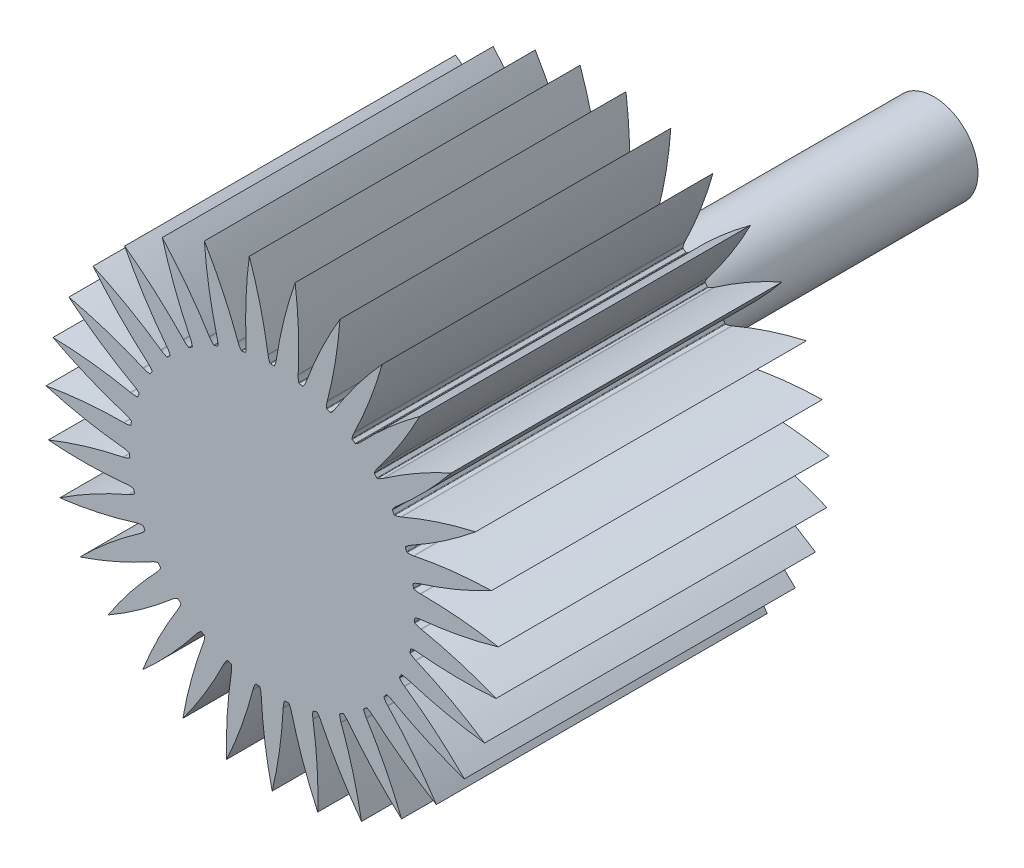
from build123d import *

# Parameters (mm, degrees)
SKETCH1_R                = 500
EXTRUDE1_DEPTH           = 300
CUT_EXTRUDE1_START       = -301
CUT_EXTRUDE1_DEPTH       = 302
FILLET1_R                = 0.635
CIRPATTERN1_COUNT        = 31
FILLET1_OF_CIRPATTERN1_R = 0.635
SKETCH3_R                = 40
EXTRUDE2_DEPTH           = 300


with BuildPart() as part:
    # Sketch1 → Extrude1 (new body)
    with BuildSketch(Plane.XY):
        Circle(SKETCH1_R)
    extrude(amount=EXTRUDE1_DEPTH)

    # Sketch2 → Cut-Extrude1 (cut)
    with BuildSketch(Plane.XY.offset(300).offset(CUT_EXTRUDE1_START)):
        with BuildLine():
            Line((-2460.940364062, 1353.146977655), (-241.231460808, 437.958196997))
            ThreePointArc((-241.231460808, 437.958196997), (-82.810970136, 318.022108626), (-3.81, 135.702159428))
            Line((-3.81, 135.702159428), (-3.732214889, 135.194159428))
            ThreePointArc((-3.732214889, 135.194159428), (-3.039845854, 132.203962215), (-1.905, 129.352159428))
            ThreePointArc((-1.905, 129.352159428), (0, 129.366186361), (1.905, 129.352159428))
            ThreePointArc((1.905, 129.352159428), (3.039845854, 132.203962215), (3.732214889, 135.194159428))
            Line((3.732214889, 135.194159428), (3.81, 135.702159428))
            ThreePointArc((3.81, 135.702159428), (82.810970136, 318.022108626), (241.231460808, 437.958196997))
            Line((241.231460808, 437.958196997), (2460.940364062, 1353.146977655))
            Line((2460.940364062, 1353.146977655), (2460.940364062, 6155.095798467))
            Line((2460.940364062, 6155.095798467), (-2460.940364062, 6155.095798467))
            Line((-2460.940364062, 6155.095798467), (-2460.940364062, 1353.146977655))
        make_face()
    cut_extrude1 = extrude(amount=CUT_EXTRUDE1_DEPTH, mode=Mode.SUBTRACT)

    # Fillet1
    fillet1_edges = [part.edges().sort_by_distance(p)[0] for p in [
        (1.905, 129.352159428, 150),
        (-1.905, 129.352159428, 150),
    ]]
    fillet(fillet1_edges, radius=FILLET1_R)

    # CirPattern1: Cut-Extrude1 ×31 about axis
    cirpattern1_axis = Axis((0, 0, 0), (0, 0, 1))
    for i in range(1, CIRPATTERN1_COUNT):
        add(cut_extrude1.rotate(cirpattern1_axis, i * 360 / CIRPATTERN1_COUNT), mode=Mode.SUBTRACT)

    # Fillet1 of CirPattern1
    fillet1_of_cirpattern1_edges = [part.edges().sort_by_distance(p)[0] for p in [
        (-24.172393725, 127.087786806, 150),
        (-27.904402801, 126.320839444, 150),
        (-49.260166811, 119.62042526, 150),
        (-52.761396073, 118.117929452, 150),
        (-72.331222879, 107.255789449, 150),
        (-75.45833159, 105.07925755, 150),
        (-92.441030185, 90.500089016, 150),
        (-95.065994147, 87.738628497, 150),
        (-108.766290853, 70.039304306, 150),
        (-110.781643733, 66.805969685, 150),
        (-120.638646795, 46.711102248, 150),
        (-121.961879808, 43.138266624, 150),
        (-127.572042362, 21.470542175, 150),
        (-128.148982194, 17.70447786, 150),
        (-129.282623525, -4.649024416, 150),
        (-129.089650192, -8.454134309, 150),
        (-125.700358892, -30.578259402, 150),
        (-124.745372744, -34.266633225, 150),
        (-116.971906796, -55.255616855, 150),
        (-115.294005079, -58.676252151, 150),
        (-103.454611093, -77.670802862, 150),
        (-101.122487299, -80.68365842, 150),
        (-85.701871456, -96.906137074, 150),
        (-82.811003008, -99.387866233, 150),
        (-64.440487132, -112.174122648, 150),
        (-61.109226524, -114.023123125, 150),
        (-40.540901693, -122.849686461, 150),
        (-36.905631126, -123.990259959, 150),
        (-14.981566976, -128.495769676, 150),
        (-11.191114854, -128.881220983, 150),
        (11.191114854, -128.881220983, 150),
        (14.981566976, -128.495769676, 150),
        (36.905631126, -123.990259959, 150),
        (40.540901693, -122.849686461, 150),
        (61.109226524, -114.023123125, 150),
        (64.440487132, -112.174122648, 150),
        (82.811003008, -99.387866233, 150),
        (85.701871456, -96.906137074, 150),
        (101.122487299, -80.68365842, 150),
        (103.454611093, -77.670802862, 150),
        (115.294005079, -58.676252151, 150),
        (116.971906796, -55.255616855, 150),
        (124.745372744, -34.266633225, 150),
        (125.700358892, -30.578259402, 150),
        (129.089650192, -8.454134309, 150),
        (129.282623525, -4.649024416, 150),
        (128.148982194, 17.70447786, 150),
        (127.572042362, 21.470542175, 150),
        (121.961879808, 43.138266624, 150),
        (120.638646795, 46.711102248, 150),
        (110.781643733, 66.805969685, 150),
        (108.766290853, 70.039304306, 150),
        (95.065994147, 87.738628497, 150),
        (92.441030185, 90.500089016, 150),
        (75.45833159, 105.07925755, 150),
        (72.331222879, 107.255789449, 150),
        (52.761396073, 118.117929452, 150),
        (49.260166811, 119.62042526, 150),
        (27.904402801, 126.320839444, 150),
        (24.172393725, 127.087786806, 150),
    ]]
    fillet(fillet1_of_cirpattern1_edges, radius=FILLET1_OF_CIRPATTERN1_R)

    # Sketch3 → Extrude2 (add)
    with BuildSketch(Plane(origin=(0, 0, 0), x_dir=(-1, 0, 0), z_dir=(0, 0, -1))):
        Circle(SKETCH3_R)
    extrude(amount=EXTRUDE2_DEPTH)


solid = part.part
